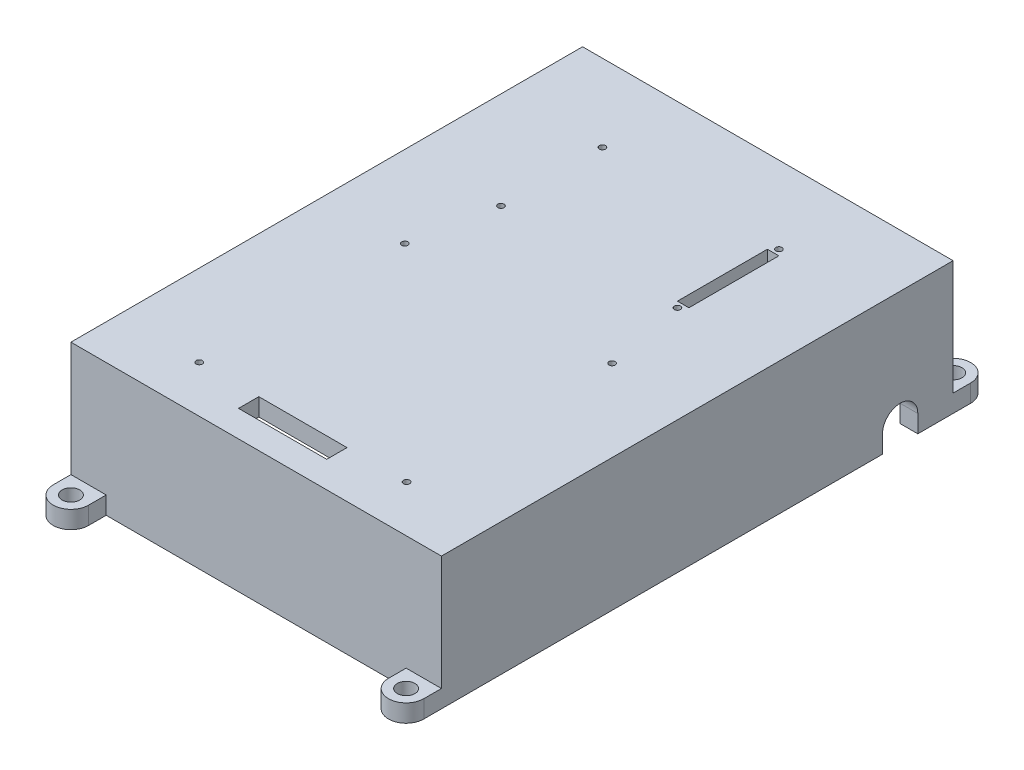
from build123d import *

# Parameters (mm, degrees)
SKETCH1_W           = 106.68
SKETCH1_H           = 147.32
BOSS_EXTRUDE1_DEPTH = 38.1
SHELL1_T            = -5.08
SKETCH5_R           = 0.889
SKETCH5_W           = 3.302
SKETCH5_H           = 25.908
SKETCH5_W_2         = 25.4
SKETCH5_H_2         = 5.842
CUT_EXTRUDE1_DEPTH  = 38.1
CUT_EXTRUDE2_DEPTH  = 107.68
SKETCH15_R          = 2.54
BOSS_EXTRUDE5_DEPTH = 5.08


with BuildPart() as part:
    # Sketch1 → Boss-Extrude1 (new body)
    with BuildSketch(Plane(origin=(0, 0, 0), x_dir=(1, 0, 0), z_dir=(0, 1, 0))):
        Rectangle(SKETCH1_W, SKETCH1_H)
    extrude(amount=BOSS_EXTRUDE1_DEPTH)

    # Shell1
    shell1_openings = [part.faces().sort_by_distance(p)[0] for p in [
        (0, 0, 0),
    ]]
    offset(amount=SHELL1_T, openings=shell1_openings, kind=Kind.INTERSECTION)

    # Sketch5 → Cut-Extrude1 (cut)
    with BuildSketch(Plane(origin=(0, 38.1, 0), x_dir=(1, 0, 0), z_dir=(0, 1, 0))):
        with Locations((-25.4, 51.435)):
            Circle(SKETCH5_R)
        with Locations((-25.4, 22.225)):
            Circle(SKETCH5_R)
        with Locations((25.4, 36.83)):
            Rectangle(SKETCH5_W, SKETCH5_H)
        with Locations((25.4, 51.435)):
            Circle(SKETCH5_R)
        with Locations((25.4, 22.225)):
            Circle(SKETCH5_R)
        with Locations((0, -63.119)):
            Rectangle(SKETCH5_W_2, SKETCH5_H_2)
        with Locations((29.845, -60.198)):
            Circle(SKETCH5_R)
        with Locations((-29.845, -60.198)):
            Circle(SKETCH5_R)
        with Locations((-29.845, -1.016)):
            Circle(SKETCH5_R)
        with Locations((29.845, -1.016)):
            Circle(SKETCH5_R)
    extrude(amount=-CUT_EXTRUDE1_DEPTH, mode=Mode.SUBTRACT)

    # Sketch6 → Cut-Extrude2 (cut, through all)
    with BuildSketch(Plane.ZY.offset(53.34)):
        with BuildLine():
            Line((-63.5, -17.421133293), (-63.5, 5.08))
            ThreePointArc((-63.5, 5.08), (-58.42, 10.16), (-53.34, 5.08))
            Line((-53.34, 5.08), (-53.34, -17.421133293))
            ThreePointArc((-53.34, -17.421133293), (-58.42, -22.501133293), (-63.5, -17.421133293))
        make_face()
    extrude(amount=-CUT_EXTRUDE2_DEPTH, mode=Mode.SUBTRACT)

    # Sketch15 → Boss-Extrude5 (add)
    with BuildSketch(Plane.XZ):
        with BuildLine():
            Line((-53.34, -73.66), (-53.34, -78.74))
            ThreePointArc((-53.34, -78.74), (-48.26, -83.82), (-43.18, -78.74))
            Line((-43.18, -78.74), (-43.18, -73.66))
            Line((-43.18, -73.66), (-53.34, -73.66))
        make_face()
        with Locations((-48.26, -78.74)):
            Circle(SKETCH15_R, mode=Mode.SUBTRACT)
        with BuildLine():
            Line((53.34, -73.66), (43.18, -73.66))
            Line((43.18, -73.66), (43.18, -78.74))
            ThreePointArc((43.18, -78.74), (48.26, -83.82), (53.34, -78.74))
            Line((53.34, -78.74), (53.34, -73.66))
        make_face()
        with Locations((48.26, -78.74)):
            Circle(SKETCH15_R, mode=Mode.SUBTRACT)
        with BuildLine():
            Line((43.18, 78.74), (43.18, 73.66))
            Line((43.18, 73.66), (53.34, 73.66))
            Line((53.34, 73.66), (53.34, 78.74))
            ThreePointArc((53.34, 78.74), (48.26, 83.82), (43.18, 78.74))
        make_face()
        with Locations((48.26, 78.74)):
            Circle(SKETCH15_R, mode=Mode.SUBTRACT)
        with BuildLine():
            Line((-53.34, 78.74), (-53.34, 73.66))
            Line((-53.34, 73.66), (-43.18, 73.66))
            Line((-43.18, 73.66), (-43.18, 78.74))
            ThreePointArc((-43.18, 78.74), (-48.26, 83.82), (-53.34, 78.74))
        make_face()
        with Locations((-48.26, 78.74)):
            Circle(SKETCH15_R, mode=Mode.SUBTRACT)
    extrude(amount=-BOSS_EXTRUDE5_DEPTH)


solid = part.part
